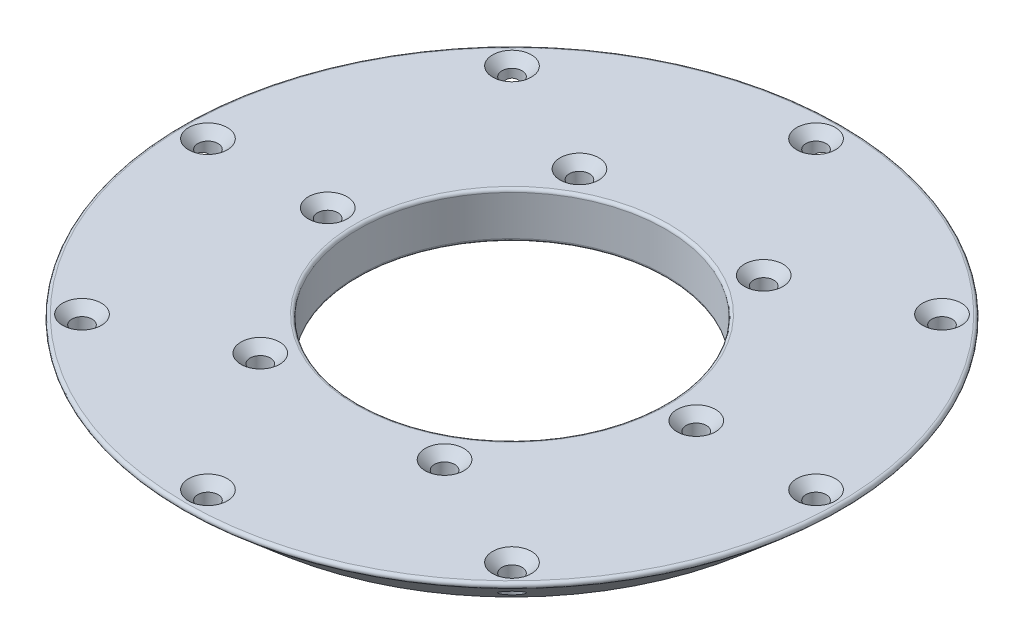
from build123d import *

# Parameters (mm, degrees)
CSK_FOR_M6_FLAT_HEAD_MACHINE_SCREW1_D           = 6.6
CSK_FOR_M6_FLAT_HEAD_MACHINE_SCREW1_DEPTH       = 15.001
CSK_FOR_M6_FLAT_HEAD_MACHINE_SCREW1_CSINK_D     = 12.6
CSK_FOR_M6_FLAT_HEAD_MACHINE_SCREW1_CSINK_ANGLE = 90
CSK_FOR_M6_FLAT_HEAD_MACHINE_SCREW2_D           = 6.6
CSK_FOR_M6_FLAT_HEAD_MACHINE_SCREW2_CSINK_D     = 12.6
CSK_FOR_M6_FLAT_HEAD_MACHINE_SCREW2_CSINK_ANGLE = 90
CIRPATTERN1_COUNT                               = 8
CIRPATTERN2_COUNT                               = 6
FINISHING_FILLET_R                              = 1


with BuildPart() as part:
    # Sketch1 → Revolve1 (revolve)
    with BuildSketch(Plane.XY):
        Polygon((109, 15), (50, 15), (50, 0), (91.582188688, 0), align=None)
    revolve(axis=Axis((0, 0, 0), (0, 1, 0)))

    # CSK for M6 Flat Head Machine Screw1
    with Locations(Plane(origin=(0, 15, 0), x_dir=(-1, 0, 0), z_dir=(0, 1, 0))):
        with Locations((-99, 0)):
            csk_for_m6_flat_head_machine_screw1 = CounterSinkHole(CSK_FOR_M6_FLAT_HEAD_MACHINE_SCREW1_D / 2, CSK_FOR_M6_FLAT_HEAD_MACHINE_SCREW1_CSINK_D / 2, depth=CSK_FOR_M6_FLAT_HEAD_MACHINE_SCREW1_DEPTH, counter_sink_angle=CSK_FOR_M6_FLAT_HEAD_MACHINE_SCREW1_CSINK_ANGLE)

    # CSK for M6 Flat Head Machine Screw2 (through all)
    with Locations(Plane(origin=(60, 15, 0), x_dir=(0, 0, 1), z_dir=(0, 1, 0))):
        with Locations((0, 0)):
            csk_for_m6_flat_head_machine_screw2 = CounterSinkHole(CSK_FOR_M6_FLAT_HEAD_MACHINE_SCREW2_D / 2, CSK_FOR_M6_FLAT_HEAD_MACHINE_SCREW2_CSINK_D / 2, counter_sink_angle=CSK_FOR_M6_FLAT_HEAD_MACHINE_SCREW2_CSINK_ANGLE)

    # CirPattern1: CSK for M6 Flat Head Machine Screw1 ×8 about axis
    cirpattern1_axis = Axis((0, 0, 0), (0, 1, 0))
    for i in range(1, CIRPATTERN1_COUNT):
        add(csk_for_m6_flat_head_machine_screw1.rotate(cirpattern1_axis, i * 360 / CIRPATTERN1_COUNT), mode=Mode.SUBTRACT)

    # CirPattern2: CSK for M6 Flat Head Machine Screw2 ×6 about axis
    cirpattern2_axis = Axis((0, 0, 0), (0, 1, 0))
    for i in range(1, CIRPATTERN2_COUNT):
        add(csk_for_m6_flat_head_machine_screw2.rotate(cirpattern2_axis, i * 360 / CIRPATTERN2_COUNT), mode=Mode.SUBTRACT)

    # Finishing Fillet
    finishing_fillet_edges = [part.edges().sort_by_distance(p)[0] for p in [
        (-109, 15, 0),
        (-50, 0, 0),
        (-50, 15, 0),
    ]]
    fillet(finishing_fillet_edges, radius=FINISHING_FILLET_R)


solid = part.part
